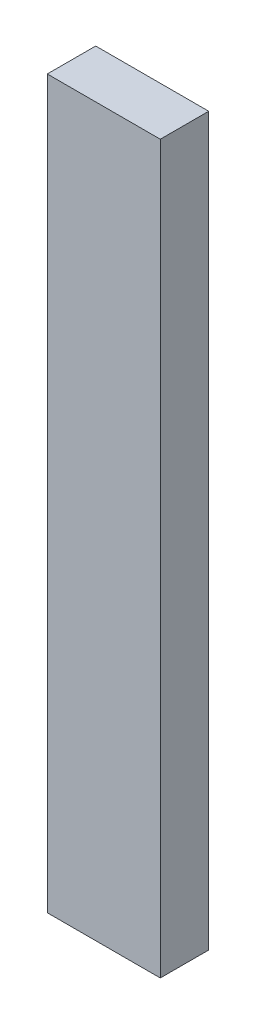
from build123d import *

# Parameters (mm, degrees)
SKETCH1_W           = 57.15
SKETCH1_H           = 8.89
BOSS_EXTRUDE1_DEPTH = 3.81


with BuildPart() as part:
    # Sketch1 → Boss-Extrude1 (new body)
    with BuildSketch(Plane(origin=(0, 0, 0), x_dir=(0, 1, 0), z_dir=(0, 0, 1))):
        with Locations((28.575, 4.445)):
            Rectangle(SKETCH1_W, SKETCH1_H)
    extrude(amount=BOSS_EXTRUDE1_DEPTH)


solid = part.part
